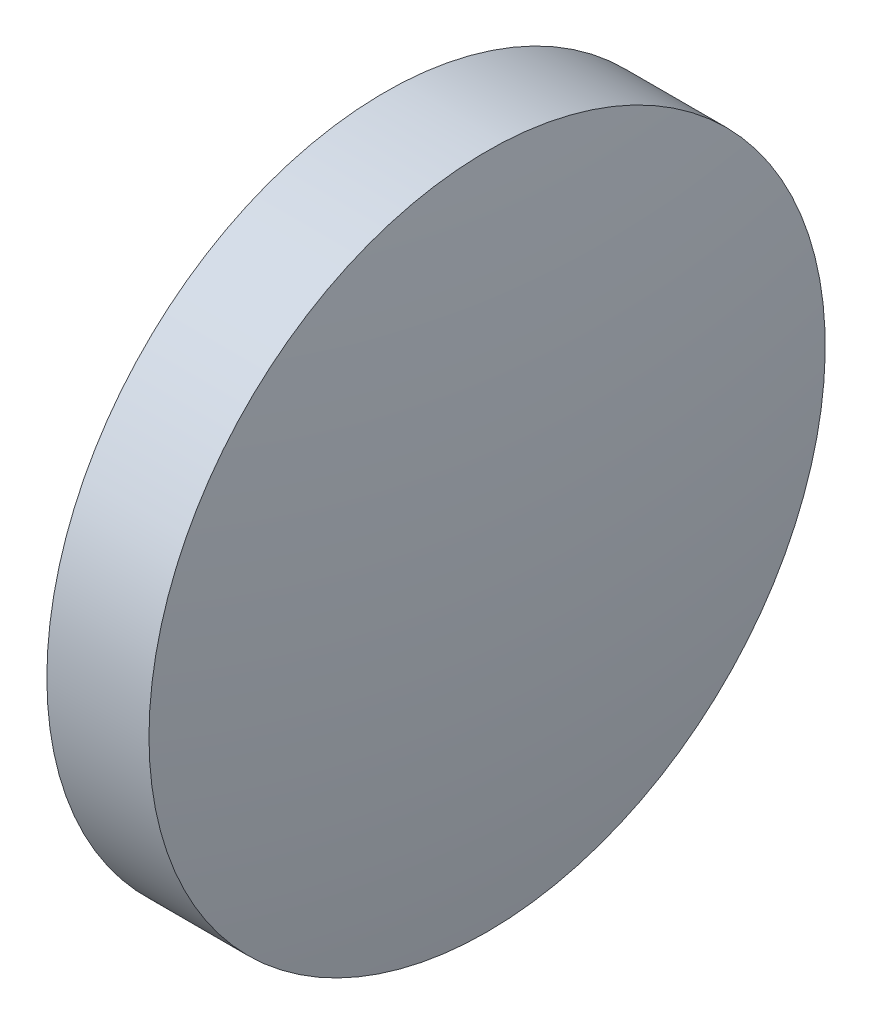
from build123d import *


with BuildPart() as part:
    # 草图1 → 旋转1 (revolve)
    with BuildSketch(Plane.XY, mode=Mode.PRIVATE) as revolve_1_sk:
        with BuildLine():
            Line((595.46776835, 196.2413411), (595.46776835, 201.2413411))
            Line((595.46776835, 201.2413411), (596.97776835, 201.2413411))
            ThreePointArc((596.97776835, 201.2413411), (597.270120501, 198.748934568), (597.36776835, 196.2413411))
            Line((597.36776835, 196.2413411), (595.46776835, 196.2413411))
        make_face()
    revolve(revolve_1_sk.sketch.rotate(Axis((594.526217878, 196.2413411, 0), (1, 0, 0)), 180), axis=Axis((594.526217878, 196.2413411, 0), (1, 0, 0)))  # turned: the seam where the file's is


solid = part.part
